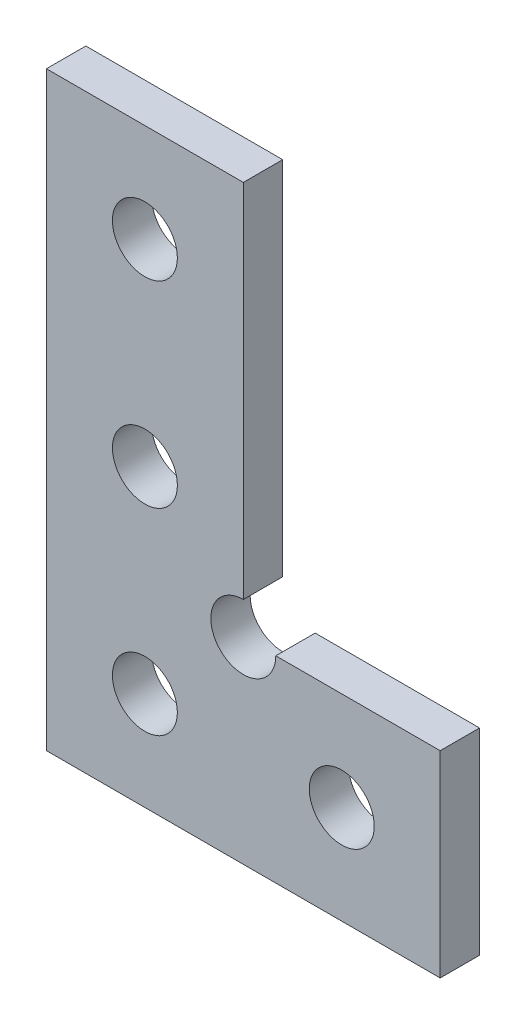
from build123d import *

# Parameters (mm, degrees)
SKETCH1_R           = 1.65
BOSS_EXTRUDE1_DEPTH = 1


with BuildPart() as part:
    # Sketch1 → Boss-Extrude1 (new body, symmetric)
    with BuildSketch(Plane.XY):
        with BuildLine():
            Line((-10, 15), (-10, -15))
            Line((-10, -15), (10, -15))
            Line((10, -15), (10, -5))
            Line((10, -5), (1.65, -5))
            ThreePointArc((1.65, -5), (-1.166726189, -6.166726189), (0, -3.35))
            Line((0, -3.35), (0, 15))
            Line((0, 15), (-10, 15))
        make_face()
        with Locations((-5, 10)):
            Circle(SKETCH1_R, mode=Mode.SUBTRACT)
        with Locations((-5, 0)):
            Circle(SKETCH1_R, mode=Mode.SUBTRACT)
        with Locations((5, -10)):
            Circle(SKETCH1_R, mode=Mode.SUBTRACT)
        with Locations((-5, -10)):
            Circle(SKETCH1_R, mode=Mode.SUBTRACT)
    extrude(amount=BOSS_EXTRUDE1_DEPTH, both=True)


solid = part.part
